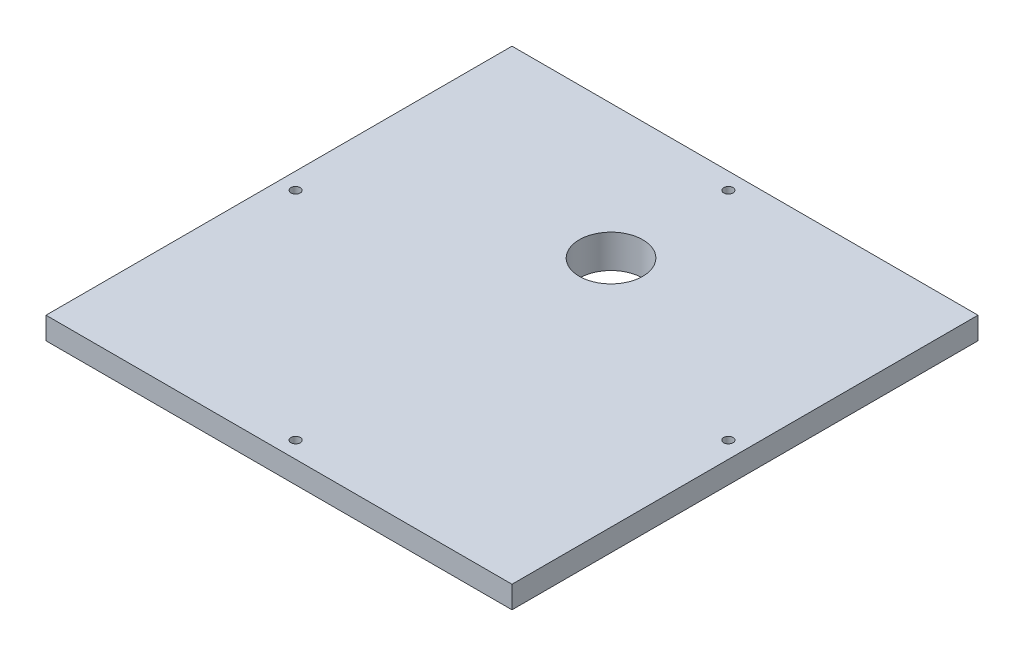
from build123d import *

# Parameters (mm, degrees)
SKETCH2_W           = 210
SKETCH2_H           = 210
BOSS_EXTRUDE1_DEPTH = 10
SKETCH3_W           = 179.6
SKETCH3_H           = 179.6
BOSS_EXTRUDE2_DEPTH = 5
BOSS_EXTRUDE2_TAPER = 2
SKETCH4_R           = 14.3
CUT_EXTRUDE1_DEPTH  = 15
SKETCH6_R           = 2.1
CUT_EXTRUDE2_DEPTH  = 10
FILLET1_R           = 5


with BuildPart() as part:
    # Sketch2 → Boss-Extrude1 (new body)
    with BuildSketch(Plane(origin=(0, 0, 0), x_dir=(1, 0, 0), z_dir=(0, 1, 0))):
        Rectangle(SKETCH2_W, SKETCH2_H)
    extrude(amount=BOSS_EXTRUDE1_DEPTH)

    # Sketch3 → Boss-Extrude2 (add)
    with BuildSketch(Plane.XZ):
        Rectangle(SKETCH3_W, SKETCH3_H)
    extrude(amount=BOSS_EXTRUDE2_DEPTH, taper=BOSS_EXTRUDE2_TAPER)

    # Sketch4 → Cut-Extrude1 (cut)
    with BuildSketch(Plane(origin=(0, 10, 0), x_dir=(1, 0, 0), z_dir=(0, 1, 0))):
        with Locations((0, 44.625396153)):
            Circle(SKETCH4_R)
    extrude(amount=-CUT_EXTRUDE1_DEPTH, mode=Mode.SUBTRACT)

    # Sketch6 → Cut-Extrude2 (cut)
    with BuildSketch(Plane(origin=(0, 10, 0), x_dir=(1, 0, 0), z_dir=(0, 1, 0))):
        with Locations((0, 97.5)):
            Circle(SKETCH6_R)
        with Locations((-97.5, 0)):
            Circle(SKETCH6_R)
        with Locations((0, -97.5)):
            Circle(SKETCH6_R)
        with Locations((97.5, 0)):
            Circle(SKETCH6_R)
        with Locations((0, 97.5)):
            Circle(SKETCH6_R)
        with Locations((0, 97.5)):
            Circle(SKETCH6_R)
        with Locations((0, 97.5)):
            Circle(SKETCH6_R)
    extrude(amount=-CUT_EXTRUDE2_DEPTH, mode=Mode.SUBTRACT)

    # Fillet1
    fillet1_edges = [part.edges().sort_by_distance(p)[0] for p in [
        (89.712698076, -2.5, -89.712698076),
        (89.712698076, -2.5, 89.712698076),
        (-89.712698076, -2.5, 89.712698076),
        (-89.712698076, -2.5, -89.712698076),
    ]]
    fillet(fillet1_edges, radius=FILLET1_R)


solid = part.part
